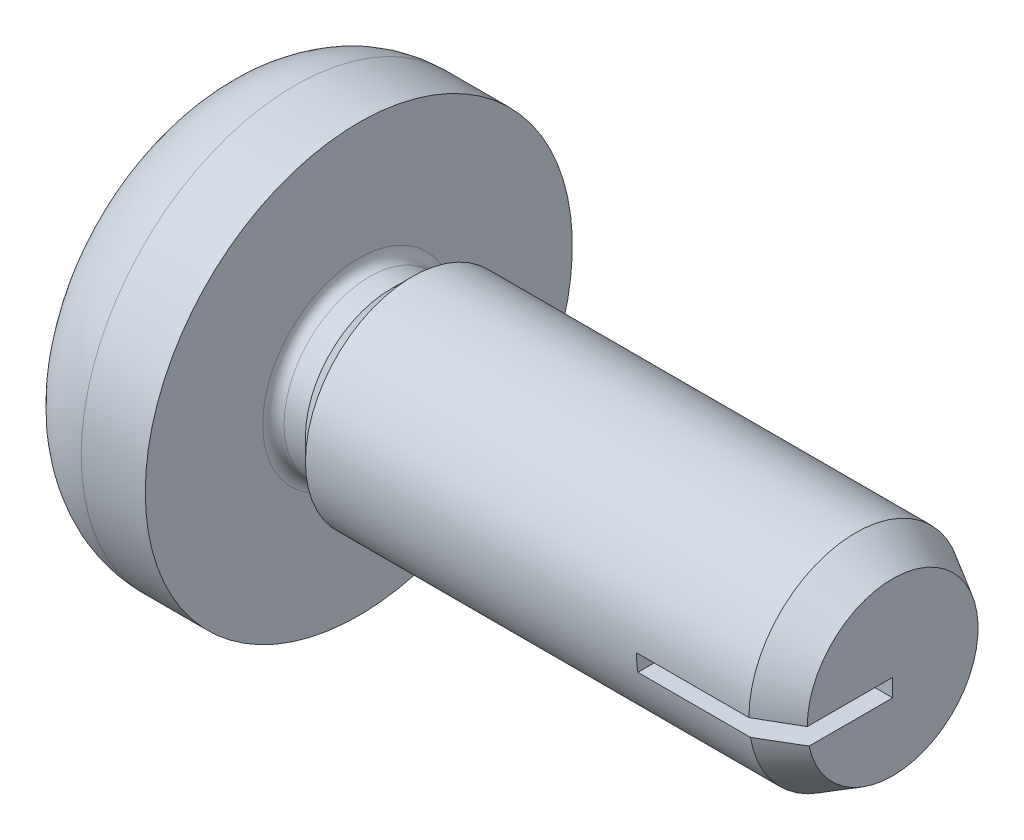
from build123d import *

# Parameters (mm, degrees)
CUT_EXTRUDE3_DEPTH         = 4
DRAFT1_ANGLE               = 20
RECESSI_CUT_EXTRUDE5_DEPTH = 4
SKETCH11_W                 = 5.6
SKETCH11_H                 = 0.666666667
POINT_CUT_EXTRUDE8_DEPTH   = 9


with BuildPart() as part:
    # Sketch1 → base-Revolve (revolve)
    with BuildSketch(Plane.XY):
        with BuildLine():
            Line((0, 0), (0, 4.8))
            ThreePointArc((0, 4.8), (0.9372583, 7.0627417), (3.2, 8))
            Line((3.2, 8), (5.6, 8))
            Line((5.6, 8), (5.6, 3.6))
            ThreePointArc((5.6, 3.6), (5.717157288, 3.317157288), (6, 3.2))
            Line((6, 3.2), (6.8, 3.2))
            Line((6.8, 3.2), (7.6, 4))
            Line((7.6, 4), (25.6, 4))
            Line((25.6, 4), (25.6, 0))
            Line((25.6, 0), (0, 0))
        make_face()
    revolve(axis=Axis((0, 0, 0), (1, 0, 0)))

    # Sketch4 → Cut-Extrude3 (cut)
    with BuildSketch(Plane(origin=(0, 0, 0), x_dir=(0, 0, -1), z_dir=(1, 0, 0))):
        Polygon((0.9, 4.39), (-0.9, 4.39), (-0.9, 0.9), (-4.39, 0.9), (-4.39, -0.9), (-0.9, -0.9), (-0.9, -4.39), (0.9, -4.39), (0.9, -0.9), (4.39, -0.9), (4.39, 0.9), (0.9, 0.9), align=None)
    extrude(amount=CUT_EXTRUDE3_DEPTH, mode=Mode.SUBTRACT)

    # Draft1
    draft1_faces = [part.faces().sort_by_distance(p)[0] for p in [
        (2, 0, -4.39),
        (2, -4.39, 0),
        (2, 0, 4.39),
        (2, 4.39, 0),
    ]]
    draft(draft1_faces, Plane(origin=(0, 0, 0), x_dir=(0, 0, -1), z_dir=(-1, 0, 0)), DRAFT1_ANGLE)

    # Sketch5 → recessI_Cut-Extrude5 (cut)
    with BuildSketch(Plane.ZY):
        Polygon((0.9, 1.778), (1.778, 0.9), (0.9, 0.9), align=None)
        Polygon((-0.9, 0.9), (-1.778, 0.9), (-0.9, 1.778), align=None)
        Polygon((-0.9, -1.778), (-1.778, -0.9), (-0.9, -0.9), align=None)
        Polygon((0.9, -0.9), (1.778, -0.9), (0.9, -1.778), align=None)
    extrude(amount=-RECESSI_CUT_EXTRUDE5_DEPTH, mode=Mode.SUBTRACT)

    # Sketch8 → point_Cut-Revolve1 (revolve, cut)
    with BuildSketch(Plane.XY):
        Polygon((25.6, 0), (26.108, 0), (26.108, 4.508), (24.214359354, 4.508), (24.214359354, 4), (25.6, 3.2), align=None)
    revolve(axis=Axis((0, 0, 0), (1, 0, 0)), mode=Mode.SUBTRACT)

    # Sketch11 → point_Cut-Extrude8 (cut, through all)
    with BuildSketch(Plane.XY):
        with Locations((22.8, -0.333333333)):
            Rectangle(SKETCH11_W, SKETCH11_H)
    extrude(amount=POINT_CUT_EXTRUDE8_DEPTH, mode=Mode.SUBTRACT)


solid = part.part
